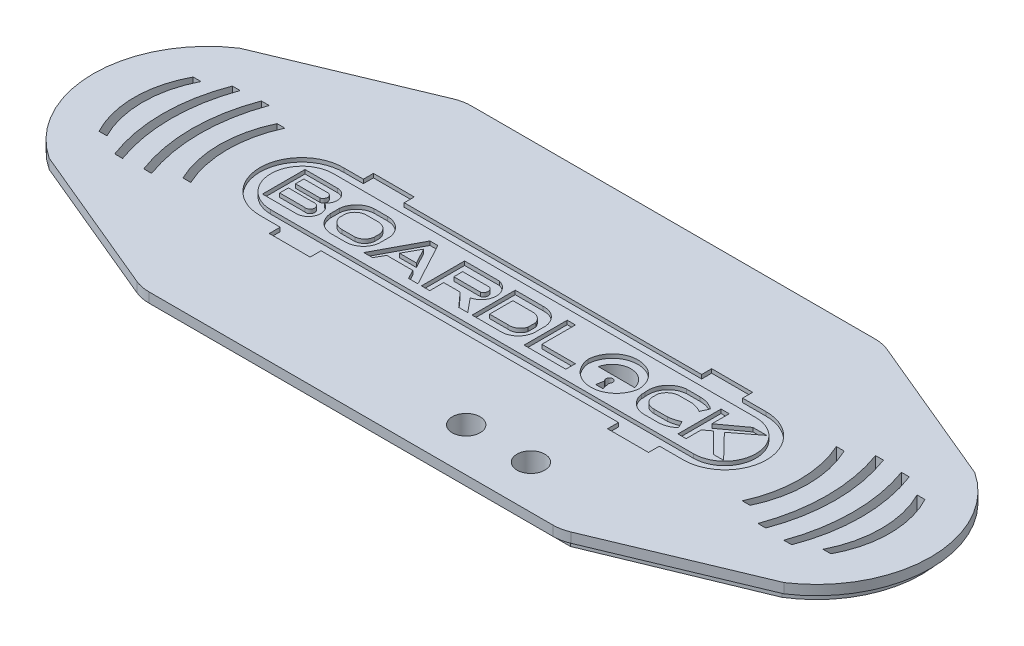
from build123d import *

# Parameters (mm, degrees)
BOSS_EXTRUDE3_DEPTH = 2.5
SKETCH2_8_R         = 3.55
BOSS_EXTRUDE4_DEPTH = 2.5
LOGO_DEPTH          = 1
FILLET1_R           = 10
SOUNDGAPS_REACH     = 178.856
BUTTONS_REACH       = 178.856
SKETCH5_R           = 3.55
CUT_EXTRUDE5_REACH  = 178.856


with BuildPart() as part:
    # Sketch2 → Boss-Extrude3 (new body)
    with BuildSketch(Plane(origin=(0, 0, 0), x_dir=(1, 0, 0), z_dir=(0, 1, 0))):
        with BuildLine():
            Line((-2.5, 2.5), (104.5, 2.5))
            Line((104.5, 2.5), (144.737244829, -14.291091061))
            ThreePointArc((144.737244829, -14.291091061), (157.8, -38.6), (144.737244829, -62.908908939))
            Line((144.737244829, -62.908908939), (104.5, -79.7))
            Line((104.5, -79.7), (-2.5, -79.7))
            Line((-2.5, -79.7), (-42.737244829, -62.908908939))
            ThreePointArc((-42.737244829, -62.908908939), (-55.8, -38.6), (-42.737244829, -14.291091061))
            Line((-42.737244829, -14.291091061), (-2.5, 2.5))
        make_face()
    extrude(amount=BOSS_EXTRUDE3_DEPTH)

    # Sketch2_8 → Boss-Extrude4 (add)
    with BuildSketch(Plane(origin=(0, 0, 0), x_dir=(1, 0, 0), z_dir=(0, 1, 0))):
        with BuildLine():
            Line((102, 0), (0, 0))
            Line((0, 0), (-2.5, 0))
            Line((-2.5, 0), (-40.702591635, -15.743739118))
            ThreePointArc((-40.702591635, -15.743739118), (-53.480653983, -38.6), (-40.702591635, -61.456260882))
            Line((-40.702591635, -61.456260882), (-2.5, -77.2))
            Line((-2.5, -77.2), (0, -77.2))
            Line((0, -77.2), (102, -77.2))
            Line((102, -77.2), (104.5, -77.2))
            Line((104.5, -77.2), (142.702591635, -61.456260882))
            ThreePointArc((142.702591635, -61.456260882), (155.480653983, -38.6), (142.702591635, -15.743739118))
            Line((142.702591635, -15.743739118), (104.5, 0))
            Line((104.5, 0), (102, 0))
        make_face()
        with Locations((69.32, -68.6)):
            Circle(SKETCH2_8_R, mode=Mode.SUBTRACT)
        with Locations((85.83, -68.6)):
            Circle(SKETCH2_8_R, mode=Mode.SUBTRACT)
    extrude(amount=-BOSS_EXTRUDE4_DEPTH)

    # Sketch3 → Logo (cut)
    # profile 1 of 10: a face of its own
    with BuildSketch(Plane(origin=(0, 2.5, 0), x_dir=(1, 0, 0), z_dir=(0, 1, 0))):
        with BuildLine():
            Line((1.949493887, -27.461955416), (-2.987330566, -27.461955416))
            ThreePointArc((-2.987330566, -27.461955416), (-13.803120325, -38.068295938), (-2.987330566, -48.674636459))
            Line((-2.987330566, -48.674636459), (1.949493887, -48.674636459))
            Line((1.949493887, -48.674636459), (1.949493887, -51.464582861))
            Line((1.949493887, -51.464582861), (12.371678844, -51.464582861))
            Line((12.371678844, -51.464582861), (12.371678844, -48.674636459))
            Line((12.371678844, -48.674636459), (88.239814758, -48.674636459))
            Line((88.239814758, -48.674636459), (88.239814758, -51.464582861))
            Line((88.239814758, -51.464582861), (98.688646078, -51.464582861))
            Line((98.688646078, -51.464582861), (98.688646078, -48.674636459))
            Line((98.688646078, -48.674636459), (104.624475689, -48.674636459))
            ThreePointArc((104.624475689, -48.674636459), (115.383426883, -38.068295938), (104.624475689, -27.461955416))
            Line((104.624475689, -27.461955416), (98.688646078, -27.461955416))
            Line((98.688646078, -27.461955416), (98.688646078, -24.902120515))
            Line((98.688646078, -24.902120515), (88.239814758, -24.902120515))
            Line((88.239814758, -24.902120515), (88.239814758, -27.461955416))
            Line((88.239814758, -27.461955416), (12.371678844, -27.461955416))
            Line((12.371678844, -27.461955416), (12.371678844, -24.902120515))
            Line((12.371678844, -24.902120515), (1.949493887, -24.902120515))
            Line((1.949493887, -24.902120515), (1.949493887, -27.461955416))
        make_face()
        with BuildLine():
            ThreePointArc((-3.194751797, -46.01575407), (-11.064312283, -37.938772353), (-2.987330566, -30.069211866))
            Line((-2.987330566, -30.069211866), (104.700239847, -30.069211866))
            ThreePointArc((104.700239847, -30.069211866), (112.673510949, -38.042482968), (104.700239847, -46.01575407))
            Line((104.700239847, -46.01575407), (-3.194751797, -46.01575407))
        make_face(mode=Mode.SUBTRACT)
    # profile 2 of 10: a face of its own
    with BuildSketch(Plane(origin=(0, 2.5, 0), x_dir=(1, 0, 0), z_dir=(0, 1, 0))):
        with BuildLine():
            Line((0.713326147, -32.762452382), (-7.630609586, -32.762452382))
            Line((-7.630609586, -32.762452382), (-7.630609586, -43.623173078))
            Line((-7.630609586, -43.623173078), (1.144127176, -43.623173078))
            ThreePointArc((1.144127176, -43.623173078), (4.072531045, -41.089719603), (2.23246662, -37.682653616))
            ThreePointArc((2.23246662, -37.682653616), (3.210405226, -34.686087135), (0.713326147, -32.762452382))
        make_face()
        with BuildLine():
            Line((-5.680668083, -41.17440933), (-5.680668083, -38.952382967))
            Line((-5.680668083, -38.952382967), (0.713326147, -38.952382967))
            ThreePointArc((0.713326147, -38.952382967), (2.127219592, -40.063396149), (0.713326147, -41.17440933))
            Line((0.713326147, -41.17440933), (-5.680668083, -41.17440933))
        make_face(mode=Mode.SUBTRACT)
        with BuildLine():
            Line((-5.680668083, -37.138483894), (-5.680668083, -35.007152484))
            Line((-5.680668083, -35.007152484), (0.600049584, -35.007152484))
            ThreePointArc((0.600049584, -35.007152484), (1.408506175, -36.072818189), (0.600049584, -37.138483894))
            Line((0.600049584, -37.138483894), (-5.680668083, -37.138483894))
        make_face(mode=Mode.SUBTRACT)
    # profile 3 of 10: a face of its own
    with BuildSketch(Plane(origin=(0, 2.5, 0), x_dir=(1, 0, 0), z_dir=(0, 1, 0))):
        with BuildLine():
            Line((5.346460441, -36.917426319), (5.346460441, -39.213930644))
            ThreePointArc((5.346460441, -39.213930644), (6.885943052, -42.434479638), (10.251793679, -43.623173078))
            Line((10.251793679, -43.623173078), (13.828264636, -43.623173078))
            ThreePointArc((13.828264636, -43.623173078), (16.716995574, -42.386317426), (18.096652452, -39.562999301))
            Line((18.096652452, -39.562999301), (18.096652452, -36.788822077))
            ThreePointArc((18.096652452, -36.788822077), (16.446939465, -33.787674903), (13.228063284, -32.618370223))
            Line((13.228063284, -32.618370223), (9.865980952, -32.618370223))
            ThreePointArc((9.865980952, -32.618370223), (6.816585637, -33.937769105), (5.346460441, -36.917426319))
        make_face()
        with BuildLine():
            ThreePointArc((7.340408181, -37.428569745), (8.31320862, -35.726361526), (10.137103318, -35.007152484))
            Line((10.137103318, -35.007152484), (13.346680486, -35.007152484))
            ThreePointArc((13.346680486, -35.007152484), (15.178018472, -35.715584435), (16.137891368, -37.428569745))
            Line((16.137891368, -37.428569745), (16.137891368, -38.787399969))
            ThreePointArc((16.137891368, -38.787399969), (15.339335986, -40.518029243), (13.608745934, -41.316669621))
            Line((13.608745934, -41.316669621), (10.291673968, -41.316669621))
            ThreePointArc((10.291673968, -41.316669621), (8.405132361, -40.657148151), (7.340408181, -38.965885242))
            Line((7.340408181, -38.965885242), (7.340408181, -37.428569745))
        make_face(mode=Mode.SUBTRACT)
    # profile 4 of 10: a face of its own
    with BuildSketch(Plane(origin=(0, 2.5, 0), x_dir=(1, 0, 0), z_dir=(0, 1, 0))):
        Polygon((24.087565187, -32.618370223), (18.222944768, -43.623173078), (20.462903956, -43.623173078), (21.766152938, -41.316669621), (28.404577439, -41.316669621), (29.646736625, -43.623173078), (32.02923867, -43.623173078), (26.102641459, -32.618370223), align=None)
        Polygon((27.243871315, -39.213930644), (22.906495797, -39.213930644), (25.095103323, -35.2239905), align=None, mode=Mode.SUBTRACT)
    # profile 5 of 10: a face of its own
    with BuildSketch(Plane(origin=(0, 2.5, 0), x_dir=(1, 0, 0), z_dir=(0, 1, 0))):
        with BuildLine():
            Line((41.793638287, -32.618370223), (32.928013354, -32.618370223))
            Line((32.928013354, -32.618370223), (32.928013354, -43.623173078))
            Line((32.928013354, -43.623173078), (35.04301538, -43.623173078))
            Line((35.04301538, -43.623173078), (35.04301538, -40.063396149))
            Line((35.04301538, -40.063396149), (39.244046803, -40.063396149))
            Line((39.244046803, -40.063396149), (42.431036158, -43.623173078))
            Line((42.431036158, -43.623173078), (44.737782461, -43.623173078))
            Line((44.737782461, -43.623173078), (41.793638287, -40.063396149))
            ThreePointArc((41.793638287, -40.063396149), (44.733866299, -36.340883186), (41.793638287, -32.618370223))
        make_face()
        with BuildLine():
            Line((35.04301538, -37.48051524), (35.04301538, -35.2239905))
            Line((35.04301538, -35.2239905), (41.793638287, -35.2239905))
            ThreePointArc((41.793638287, -35.2239905), (42.65693054, -36.35225287), (41.793638287, -37.48051524))
            Line((41.793638287, -37.48051524), (35.04301538, -37.48051524))
        make_face(mode=Mode.SUBTRACT)
    # profile 6 of 10: a face of its own
    with BuildSketch(Plane(origin=(0, 2.5, 0), x_dir=(1, 0, 0), z_dir=(0, 1, 0))):
        with BuildLine():
            Line((52.968722487, -32.618370223), (45.846335848, -32.618370223))
            Line((45.846335848, -32.618370223), (45.846335848, -43.623173078))
            Line((45.846335848, -43.623173078), (52.83287315, -43.623173078))
            ThreePointArc((52.83287315, -43.623173078), (56.080236632, -42.589880341), (57.64582107, -39.562999301))
            Line((57.64582107, -39.562999301), (57.64582107, -36.788822077))
            ThreePointArc((57.64582107, -36.788822077), (56.171000638, -33.734937317), (52.968722487, -32.618370223))
        make_face()
        with BuildLine():
            Line((47.864668846, -41.17440933), (47.864668846, -35.2239905))
            Line((47.864668846, -35.2239905), (52.599988574, -35.2239905))
            ThreePointArc((52.599988574, -35.2239905), (54.440160348, -35.663250015), (55.624586826, -37.138483894))
            Line((55.624586826, -37.138483894), (55.624586826, -39.18661223))
            ThreePointArc((55.624586826, -39.18661223), (54.462155657, -40.712863912), (52.599988574, -41.17440933))
            Line((52.599988574, -41.17440933), (47.864668846, -41.17440933))
        make_face(mode=Mode.SUBTRACT)
    # profile 7 of 10: a face of its own
    with BuildSketch(Plane(origin=(0, 2.5, 0), x_dir=(1, 0, 0), z_dir=(0, 1, 0))):
        Polygon((61.195413218, -32.618370223), (59.109629375, -32.618370223), (59.109629375, -43.623173078), (69.752475136, -43.623173078), (69.752475136, -41.187576484), (61.195413218, -41.187576484), align=None)
    # profile 8 of 10: a face of its own
    with BuildSketch(Plane(origin=(0, 2.5, 0), x_dir=(1, 0, 0), z_dir=(0, 1, 0))):
        with BuildLine():
            ThreePointArc((86.967057925, -37.33302991), (88.24698918, -35.587564651), (90.332173753, -35.007152484))
            Line((90.332173753, -35.007152484), (93.354874286, -35.007152484))
            ThreePointArc((93.354874286, -35.007152484), (94.768458464, -35.327728442), (96.082389221, -35.939753883))
            Line((96.082389221, -35.939753883), (96.979753441, -33.956106658))
            ThreePointArc((96.979753441, -33.956106658), (95.096667996, -32.952004021), (92.988844144, -32.618370223))
            Line((92.988844144, -32.618370223), (89.529268924, -32.618370223))
            ThreePointArc((89.529268924, -32.618370223), (85.927201794, -34.605805074), (84.941711164, -38.6))
            Line((84.941711164, -38.6), (84.941711164, -39.513929713))
            ThreePointArc((84.941711164, -39.513929713), (86.739352365, -42.572399213), (90.127806859, -43.623173078))
            Line((90.127806859, -43.623173078), (93.049792527, -43.623173078))
            ThreePointArc((93.049792527, -43.623173078), (95.178031827, -43.279186153), (97.039888867, -42.192347671))
            Line((97.039888867, -42.192347671), (96.15967403, -40.380436784))
            ThreePointArc((96.15967403, -40.380436784), (94.749505142, -40.914672607), (93.266431414, -41.187576484))
            Line((93.266431414, -41.187576484), (89.766541153, -41.187576484))
            ThreePointArc((89.766541153, -41.187576484), (87.98359415, -40.626914615), (86.967057925, -39.058509102))
            Line((86.967057925, -39.058509102), (86.967057925, -37.33302991))
        make_face()
    # profile 9 of 10: a face of its own
    with BuildSketch(Plane(origin=(0, 2.5, 0), x_dir=(1, 0, 0), z_dir=(0, 1, 0))):
        Polygon((100.433477861, -32.619456407), (98.346127272, -32.619456407), (98.346127272, -43.625930338), (100.433477861, -43.625930338), (100.433477861, -39.738654566), (102.223113581, -38.43184366), (107.375394287, -43.625930338), (110.007271118, -43.625930338), (103.904039503, -37.33302991), (110.007271118, -32.619456407), (106.490539146, -32.619456407), (100.433477861, -37.042386537), align=None)
    # profile 10 of 10: a face of its own
    with BuildSketch(Plane(origin=(0, 2.5, 0), x_dir=(1, 0, 0), z_dir=(0, 1, 0))):
        with BuildLine():
            ThreePointArc((83.440446503, -38.6), (76.914090873, -32.366505687), (70.387735243, -38.6))
            ThreePointArc((70.387735243, -38.6), (76.914090873, -44.419626268), (83.440446503, -38.6))
        make_face()
        with BuildLine():
            Line((75.957169691, -42.192347671), (76.285044547, -40.252788166))
            ThreePointArc((76.285044547, -40.252788166), (76.809249819, -38.728957059), (77.33345509, -40.252788166))
            Line((77.33345509, -40.252788166), (77.846095102, -42.192347671))
            Line((77.846095102, -42.192347671), (75.957169691, -42.192347671))
        make_face(mode=Mode.SUBTRACT)
        with BuildLine():
            Line((81.605728053, -37.905608877), (72.327294748, -37.905608877))
            ThreePointArc((72.327294748, -37.905608877), (76.9665114, -34.227223026), (81.605728053, -37.905608877))
        make_face(mode=Mode.SUBTRACT)
    extrude(amount=-LOGO_DEPTH, mode=Mode.SUBTRACT)

    # Fillet1
    fillet1_edges = [part.edges().sort_by_distance(p)[0] for p in [
        (-2.5, 1.25, -2.5),
        (104.5, 1.25, -2.5),
        (104.5, 1.25, 79.7),
        (-2.5, 1.25, 79.7),
    ]]
    fillet(fillet1_edges, radius=FILLET1_R)

    # Sketch4 → SoundGaps (cut, up to next)
    with BuildSketch(Plane(origin=(0, 2.5, 0), x_dir=(1, 0, 0), z_dir=(0, 1, 0)), mode=Mode.PRIVATE) as soundgaps_sk1:
        with BuildLine():
            Line((-42.336442958, -26.6), (-40.336442958, -26.6))
            ThreePointArc((-40.336442958, -26.6), (-43.210098634, -38.6), (-40.336442958, -50.6))
            Line((-40.336442958, -50.6), (-42.336442958, -50.6))
            ThreePointArc((-42.336442958, -50.6), (-45.345121926, -38.6), (-42.336442958, -26.6))
        make_face()
    soundgaps_tool1 = extrude(soundgaps_sk1.sketch, amount=-SOUNDGAPS_REACH, mode=Mode.PRIVATE) & part.part
    # Sketch4 → SoundGaps (cut, up to next)
    with BuildSketch(Plane(origin=(0, 2.5, 0), x_dir=(1, 0, 0), z_dir=(0, 1, 0)), mode=Mode.PRIVATE) as soundgaps_sk2:
        with BuildLine():
            Line((-35.336442958, -53.6), (-33.336442958, -53.6))
            ThreePointArc((-33.336442958, -53.6), (-35.959167646, -38.6), (-33.336442958, -23.6))
            Line((-33.336442958, -23.6), (-35.336442958, -23.6))
            ThreePointArc((-35.336442958, -23.6), (-38.112185635, -38.6), (-35.336442958, -53.6))
        make_face()
    soundgaps_tool2 = extrude(soundgaps_sk2.sketch, amount=-SOUNDGAPS_REACH, mode=Mode.PRIVATE) & part.part
    # Sketch4 → SoundGaps (cut, up to next)
    with BuildSketch(Plane(origin=(0, 2.5, 0), x_dir=(1, 0, 0), z_dir=(0, 1, 0)), mode=Mode.PRIVATE) as soundgaps_sk3:
        with BuildLine():
            Line((-28.336442958, -23.2), (-26.336442958, -23.2))
            ThreePointArc((-26.336442958, -23.2), (-28.980435332, -38.2), (-26.336442958, -53.2))
            Line((-26.336442958, -53.2), (-28.336442958, -53.2))
            ThreePointArc((-28.336442958, -53.2), (-31.075866522, -38.2), (-28.336442958, -23.2))
        make_face()
    soundgaps_tool3 = extrude(soundgaps_sk3.sketch, amount=-SOUNDGAPS_REACH, mode=Mode.PRIVATE) & part.part
    # Sketch4 → SoundGaps (cut, up to next)
    with BuildSketch(Plane(origin=(0, 2.5, 0), x_dir=(1, 0, 0), z_dir=(0, 1, 0)), mode=Mode.PRIVATE) as soundgaps_sk4:
        with BuildLine():
            Line((-21.336442958, -50.2), (-19.336442958, -50.2))
            ThreePointArc((-19.336442958, -50.2), (-21.944289857, -38.2), (-19.336442958, -26.2))
            Line((-19.336442958, -26.2), (-21.336442958, -26.2))
            ThreePointArc((-21.336442958, -26.2), (-24.039371453, -38.2), (-21.336442958, -50.2))
        make_face()
    soundgaps_tool4 = extrude(soundgaps_sk4.sketch, amount=-SOUNDGAPS_REACH, mode=Mode.PRIVATE) & part.part
    # Sketch4 → SoundGaps (cut, up to next)
    with BuildSketch(Plane(origin=(0, 2.5, 0), x_dir=(1, 0, 0), z_dir=(0, 1, 0)), mode=Mode.PRIVATE) as soundgaps_sk5:
        with BuildLine():
            Line((123.336442958, -26.2), (121.336442958, -26.2))
            ThreePointArc((121.336442958, -26.2), (123.944289857, -38.2), (121.336442958, -50.2))
            Line((121.336442958, -50.2), (123.336442958, -50.2))
            ThreePointArc((123.336442958, -50.2), (126.039371453, -38.2), (123.336442958, -26.2))
        make_face()
    soundgaps_tool5 = extrude(soundgaps_sk5.sketch, amount=-SOUNDGAPS_REACH, mode=Mode.PRIVATE) & part.part
    # Sketch4 → SoundGaps (cut, up to next)
    with BuildSketch(Plane(origin=(0, 2.5, 0), x_dir=(1, 0, 0), z_dir=(0, 1, 0)), mode=Mode.PRIVATE) as soundgaps_sk6:
        with BuildLine():
            Line((130.336442958, -53.2), (128.336442958, -53.2))
            ThreePointArc((128.336442958, -53.2), (130.980435332, -38.2), (128.336442958, -23.2))
            Line((128.336442958, -23.2), (130.336442958, -23.2))
            ThreePointArc((130.336442958, -23.2), (133.075866522, -38.2), (130.336442958, -53.2))
        make_face()
    soundgaps_tool6 = extrude(soundgaps_sk6.sketch, amount=-SOUNDGAPS_REACH, mode=Mode.PRIVATE) & part.part
    # Sketch4 → SoundGaps (cut, up to next)
    with BuildSketch(Plane(origin=(0, 2.5, 0), x_dir=(1, 0, 0), z_dir=(0, 1, 0)), mode=Mode.PRIVATE) as soundgaps_sk7:
        with BuildLine():
            Line((137.336442958, -23.6), (135.336442958, -23.6))
            ThreePointArc((135.336442958, -23.6), (137.959167646, -38.6), (135.336442958, -53.6))
            Line((135.336442958, -53.6), (137.336442958, -53.6))
            ThreePointArc((137.336442958, -53.6), (140.112185635, -38.6), (137.336442958, -23.6))
        make_face()
    soundgaps_tool7 = extrude(soundgaps_sk7.sketch, amount=-SOUNDGAPS_REACH, mode=Mode.PRIVATE) & part.part
    # Sketch4 → SoundGaps (cut, up to next)
    with BuildSketch(Plane(origin=(0, 2.5, 0), x_dir=(1, 0, 0), z_dir=(0, 1, 0)), mode=Mode.PRIVATE) as soundgaps_sk8:
        with BuildLine():
            Line((144.336442958, -50.6), (142.336442958, -50.6))
            ThreePointArc((142.336442958, -50.6), (145.210098634, -38.6), (142.336442958, -26.6))
            Line((142.336442958, -26.6), (144.336442958, -26.6))
            ThreePointArc((144.336442958, -26.6), (147.345121926, -38.6), (144.336442958, -50.6))
        make_face()
    soundgaps_tool8 = extrude(soundgaps_sk8.sketch, amount=-SOUNDGAPS_REACH, mode=Mode.PRIVATE) & part.part
    add(soundgaps_tool1.solids().sort_by_distance((-43.336866, 2.5, 38.6))[0], mode=Mode.SUBTRACT)
    add(soundgaps_tool2.solids().sort_by_distance((-36.164676, 2.5, 38.6))[0], mode=Mode.SUBTRACT)
    add(soundgaps_tool3.solids().sort_by_distance((-29.153278, 2.5, 38.2))[0], mode=Mode.SUBTRACT)
    add(soundgaps_tool4.solids().sort_by_distance((-22.134482, 2.5, 38.2))[0], mode=Mode.SUBTRACT)
    add(soundgaps_tool5.solids().sort_by_distance((124.134482, 2.5, 38.2))[0], mode=Mode.SUBTRACT)
    add(soundgaps_tool6.solids().sort_by_distance((131.153278, 2.5, 38.2))[0], mode=Mode.SUBTRACT)
    add(soundgaps_tool7.solids().sort_by_distance((138.164676, 2.5, 38.6))[0], mode=Mode.SUBTRACT)
    add(soundgaps_tool8.solids().sort_by_distance((145.336866, 2.5, 38.6))[0], mode=Mode.SUBTRACT)

    # Sketch5 → Buttons (cut, up to next)
    with BuildSketch(Plane(origin=(0, 2.5, 0), x_dir=(1, 0, 0), z_dir=(0, 1, 0)), mode=Mode.PRIVATE) as buttons_sk1:
        with Locations((69.32, -68.6)):
            Circle(SKETCH5_R)
    buttons_tool1 = extrude(buttons_sk1.sketch, amount=-BUTTONS_REACH, mode=Mode.PRIVATE) & part.part
    # Sketch5 → Buttons (cut, up to next)
    with BuildSketch(Plane(origin=(0, 2.5, 0), x_dir=(1, 0, 0), z_dir=(0, 1, 0)), mode=Mode.PRIVATE) as buttons_sk2:
        with Locations((85.83, -68.6)):
            Circle(SKETCH5_R)
    buttons_tool2 = extrude(buttons_sk2.sketch, amount=-BUTTONS_REACH, mode=Mode.PRIVATE) & part.part
    add(buttons_tool1.solids().sort_by_distance((69.32, 2.5, 68.6))[0], mode=Mode.SUBTRACT)
    add(buttons_tool2.solids().sort_by_distance((85.83, 2.5, 68.6))[0], mode=Mode.SUBTRACT)

    # Sketch3_5 → Cut-Extrude5 (cut, up to next)
    with BuildSketch(Plane(origin=(0, 2.5, 0), x_dir=(1, 0, 0), z_dir=(0, 1, 0)), mode=Mode.PRIVATE) as cut_extrude5_sk1:
        with BuildLine():
            ThreePointArc((81.605728053, -37.905608877), (76.9665114, -34.227223026), (72.327294748, -37.905608877))
            Line((72.327294748, -37.905608877), (81.605728053, -37.905608877))
        make_face()
    cut_extrude5_tool1 = extrude(cut_extrude5_sk1.sketch, amount=-CUT_EXTRUDE5_REACH, mode=Mode.PRIVATE) & part.part
    # Sketch3_5 → Cut-Extrude5 (cut, up to next)
    with BuildSketch(Plane(origin=(0, 2.5, 0), x_dir=(1, 0, 0), z_dir=(0, 1, 0)), mode=Mode.PRIVATE) as cut_extrude5_sk2:
        with BuildLine():
            ThreePointArc((77.33345509, -40.252788166), (76.809249819, -38.728957059), (76.285044547, -40.252788166))
            Line((76.285044547, -40.252788166), (75.957169691, -42.192347671))
            Line((75.957169691, -42.192347671), (77.846095102, -42.192347671))
            Line((77.846095102, -42.192347671), (77.33345509, -40.252788166))
        make_face()
    cut_extrude5_tool2 = extrude(cut_extrude5_sk2.sketch, amount=-CUT_EXTRUDE5_REACH, mode=Mode.PRIVATE) & part.part
    add(cut_extrude5_tool1.solids().sort_by_distance((76.966511, 2.5, 36.371206))[0], mode=Mode.SUBTRACT)
    add(cut_extrude5_tool2.solids().sort_by_distance((76.838073, 2.5, 40.549632))[0], mode=Mode.SUBTRACT)


solid = part.part
